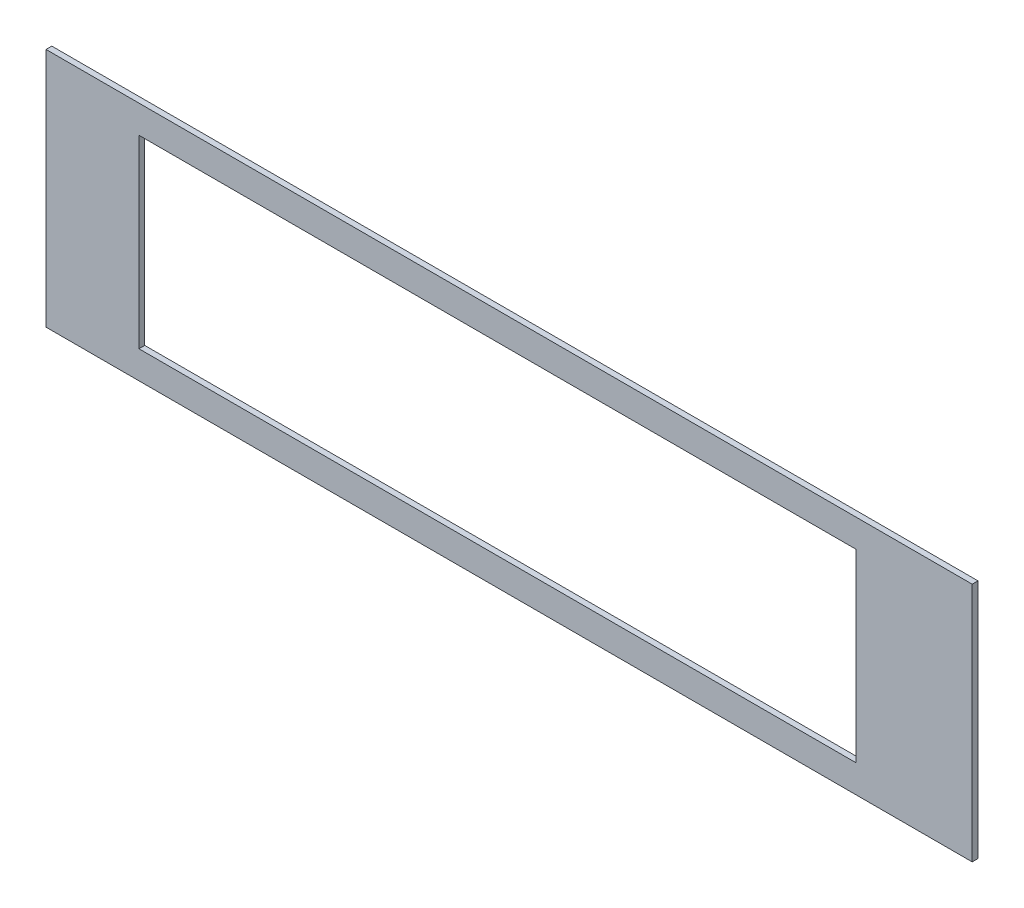
from build123d import *

# Parameters (mm, degrees)
SKETCH1_W           = 508.2032
SKETCH1_H           = 131.97205
SKETCH1_W_2         = 393.4968
SKETCH1_H_2         = 101.4476
BOSS_EXTRUDE1_DEPTH = 3.175


with BuildPart() as part:
    # Sketch1 → Boss-Extrude1 (new body)
    with BuildSketch(Plane.XY):
        Rectangle(SKETCH1_W, SKETCH1_H)
        with Locations((-6.35, -0.0254)):
            Rectangle(SKETCH1_W_2, SKETCH1_H_2, mode=Mode.SUBTRACT)
    extrude(amount=BOSS_EXTRUDE1_DEPTH)


solid = part.part
